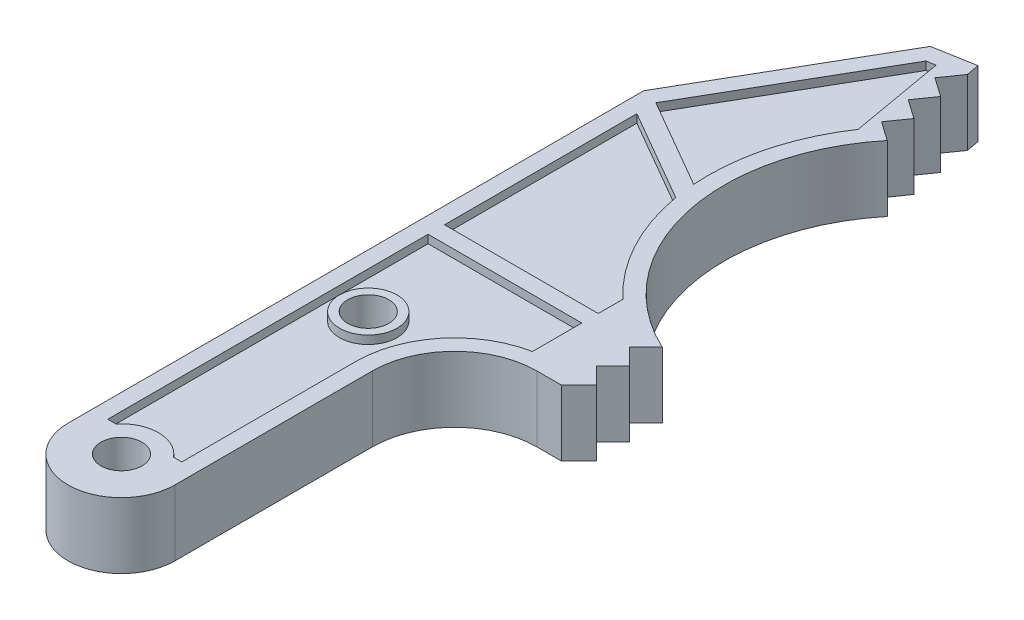
from build123d import *

# Parameters (mm, degrees)
CROQUIS2_R              = 2.5
SALIENTE_EXTRUIR1_DEPTH = 8
CROQUIS3_R              = 3.5
CORTAR_EXTRUIR1_DEPTH   = 1
CROQUIS4_R              = 3.5
CORTAR_EXTRUIR2_DEPTH   = 1


with BuildPart() as part:
    # Croquis2 → Saliente-Extruir1 (new body)
    with BuildSketch(Plane(origin=(0, 0, 0), x_dir=(1, 0, 0), z_dir=(0, 1, 0))):
        with BuildLine():
            Line((-6.5, 70), (-6.5, 0))
            ThreePointArc((-6.5, 0), (0, -6.5), (6.5, 0))
            Line((6.5, 0), (6.5, 24))
            ThreePointArc((6.5, 24), (9.428932188, 31.071067812), (16.5, 34))
            Line((16.5, 34), (19.5, 34))
            Line((19.5, 34), (21.621320344, 36.121320344))
            Line((21.621320344, 36.121320344), (19.621320344, 38.121320344))
            Line((19.621320344, 38.121320344), (21.621320344, 40.121320344))
            Line((21.621320344, 40.121320344), (19.621320344, 42.121320344))
            Line((19.621320344, 42.121320344), (21.621320344, 44.121320344))
            ThreePointArc((21.621320344, 44.121320344), (8.897927721, 59.859277281), (13.535653981, 79.558503244))
            Line((13.535653981, 79.558503244), (11.21874212, 81.180822395))
            Line((11.21874212, 81.180822395), (12.841061271, 83.497734256))
            Line((12.841061271, 83.497734256), (10.524149409, 85.120053407))
            Line((10.524149409, 85.120053407), (12.14646856, 87.436965268))
            Line((12.14646856, 87.436965268), (9.829556699, 89.059284419))
            Line((9.829556699, 89.059284419), (11.451875849, 91.37619628))
            Line((11.451875849, 91.37619628), (11.174038765, 92.951888685))
            Line((11.174038765, 92.951888685), (6.25, 92.083647797))
            Line((6.25, 92.083647797), (-6.5, 70))
        make_face()
        Circle(CROQUIS2_R, mode=Mode.SUBTRACT)
        with Locations((0, 30)):
            Circle(CROQUIS2_R, mode=Mode.SUBTRACT)
    extrude(amount=SALIENTE_EXTRUIR1_DEPTH)

    # Croquis3 → Cortar-Extruir1 (cut)
    with BuildSketch(Plane(origin=(0, 8, 0), x_dir=(1, 0, 0), z_dir=(0, 1, 0))):
        with BuildLine():
            Line((7.515743149, 90.275979241), (-4.5, 69.464101615))
            Line((-4.5, 69.464101615), (6.386283079, 63.178903149))
            ThreePointArc((6.386283079, 63.178903149), (7.166644063, 71.420557609), (10.59569924, 78.955503667))
            Line((10.59569924, 78.955503667), (8.566911861, 90.461328646))
            Line((8.566911861, 90.461328646), (7.515743149, 90.275979241))
        make_face()
        with BuildLine():
            Line((-4.5, 67.154700538), (-4.5, 43.774315056))
            Line((-4.5, 43.774315056), (14.183644035, 43.774315056))
            Line((14.183644035, 43.774315056), (14.183644035, 46.774315056))
            ThreePointArc((14.183644035, 46.774315056), (9.308263877, 53.126130169), (6.691099089, 60.693516467))
            Line((6.691099089, 60.693516467), (-4.5, 67.154700538))
        make_face()
        with BuildLine():
            Line((-4.5, 2.828427125), (-4.5, 41.774315056))
            Line((-4.5, 41.774315056), (14.183644035, 41.774315056))
            Line((14.183644035, 41.774315056), (14.183644035, 35.774315056))
            ThreePointArc((14.183644035, 35.774315056), (7.231875282, 31.622457885), (4.5, 24))
            Line((4.5, 24), (4.5, 2.828427125))
            Line((4.5, 2.828427125), (3.5, 2.828427125))
            ThreePointArc((3.5, 2.828427125), (0, 4.5), (-3.5, 2.828427125))
            Line((-3.5, 2.828427125), (-4.5, 2.828427125))
        make_face()
        with Locations((0, 30)):
            Circle(CROQUIS3_R, mode=Mode.SUBTRACT)
    extrude(amount=-CORTAR_EXTRUIR1_DEPTH, mode=Mode.SUBTRACT)

    # Croquis4 → Cortar-Extruir2 (cut)
    with BuildSketch(Plane.XZ):
        with BuildLine():
            Line((4.5, -24), (4.5, -2.828427125))
            Line((4.5, -2.828427125), (3.5, -2.828427125))
            ThreePointArc((3.5, -2.828427125), (0, -4.5), (-3.5, -2.828427125))
            Line((-3.5, -2.828427125), (-4.5, -2.828427125))
            Line((-4.5, -2.828427125), (-4.5, -41.774315056))
            Line((-4.5, -41.774315056), (14.183644035, -41.774315056))
            Line((14.183644035, -41.774315056), (14.183644035, -35.774315056))
            ThreePointArc((14.183644035, -35.774315056), (7.231875282, -31.622457885), (4.5, -24))
        make_face()
        with Locations((0, -30)):
            Circle(CROQUIS4_R, mode=Mode.SUBTRACT)
        with BuildLine():
            Line((6.386283079, -63.178903149), (-4.5, -69.464101615))
            Line((-4.5, -69.464101615), (7.515743149, -90.275979241))
            Line((7.515743149, -90.275979241), (8.566911861, -90.461328646))
            Line((8.566911861, -90.461328646), (10.59569924, -78.955503667))
            ThreePointArc((10.59569924, -78.955503667), (7.166644063, -71.420557609), (6.386283079, -63.178903149))
        make_face()
        with BuildLine():
            Line((-4.5, -67.154700538), (6.691099089, -60.693516467))
            ThreePointArc((6.691099089, -60.693516467), (9.308263877, -53.126130169), (14.183644035, -46.774315056))
            Line((14.183644035, -46.774315056), (14.183644035, -43.774315056))
            Line((14.183644035, -43.774315056), (-4.5, -43.774315056))
            Line((-4.5, -43.774315056), (-4.5, -67.154700538))
        make_face()
    extrude(amount=-CORTAR_EXTRUIR2_DEPTH, mode=Mode.SUBTRACT)


solid = part.part
